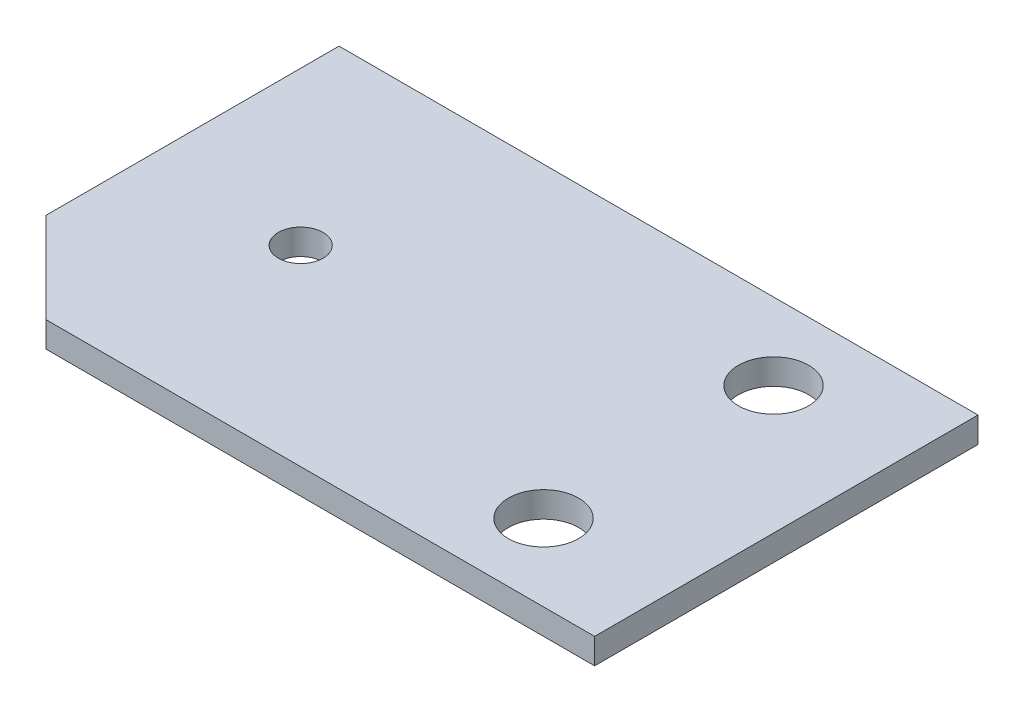
from build123d import *

# Parameters (mm, degrees)
SKETCH_1_W          = 50
SKETCH_1_H          = 30
EXTRUDE_1_DEPTH     = 2
SKETCH_2_R          = 2.75
SKETCH_2_R_2        = 1.75
CUT_EXTRUDE_1_DEPTH = 3


with BuildPart() as part:
    # 草图1 → 凸台-拉伸1 (new body)
    with BuildSketch(Plane(origin=(0, 0, 0), x_dir=(1, 0, 0), z_dir=(0, 1, 0))):
        with Locations((25, 15)):
            Rectangle(SKETCH_1_W, SKETCH_1_H)
    extrude(amount=EXTRUDE_1_DEPTH)

    # 草图2 → 切除-拉伸1 (cut, through all)
    with BuildSketch(Plane(origin=(0, 2, 0), x_dir=(1, 0, 0), z_dir=(0, 1, 0))):
        with Locations((40, 6)):
            Circle(SKETCH_2_R)
        with Locations((12, 15)):
            Circle(SKETCH_2_R_2)
        with Locations((40, 24)):
            Circle(SKETCH_2_R)
        Polygon((0, 7.071067812), (7.071067812, 0), (0, 0), align=None)
    extrude(amount=-CUT_EXTRUDE_1_DEPTH, mode=Mode.SUBTRACT)


solid = part.part
